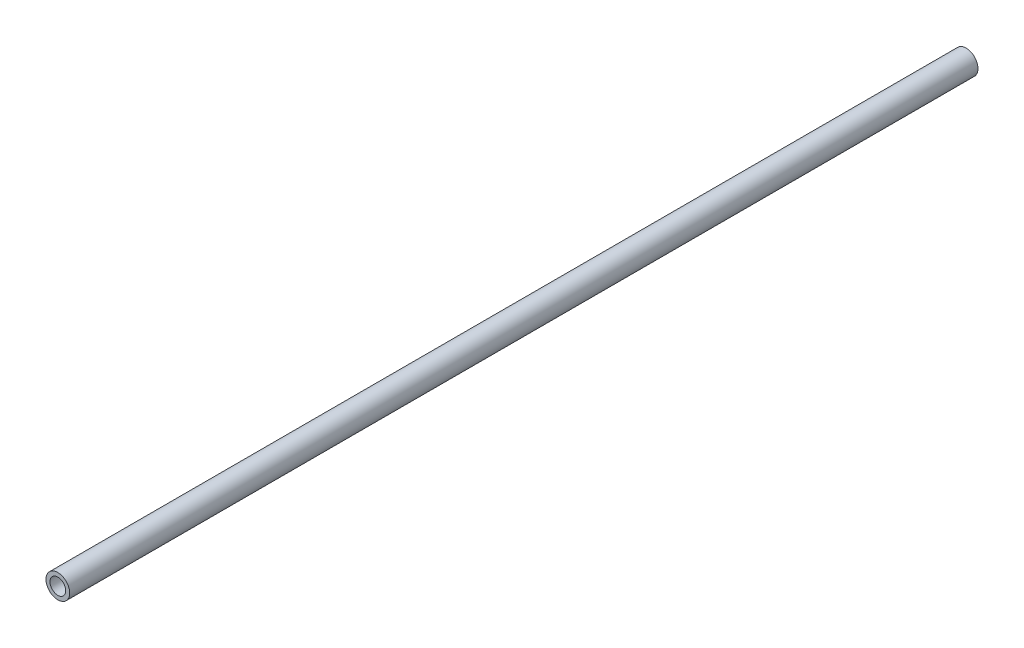
from build123d import *

# Parameters (mm, degrees)
SKETCH1_R           = 7.62
SKETCH1_R_2         = 5.08
BOSS_EXTRUDE1_DEPTH = 584.2


with BuildPart() as part:
    # Sketch1 → Boss-Extrude1 (new body)
    with BuildSketch(Plane.XY):
        Circle(SKETCH1_R)
        Circle(SKETCH1_R_2, mode=Mode.SUBTRACT)
    extrude(amount=BOSS_EXTRUDE1_DEPTH)


solid = part.part
